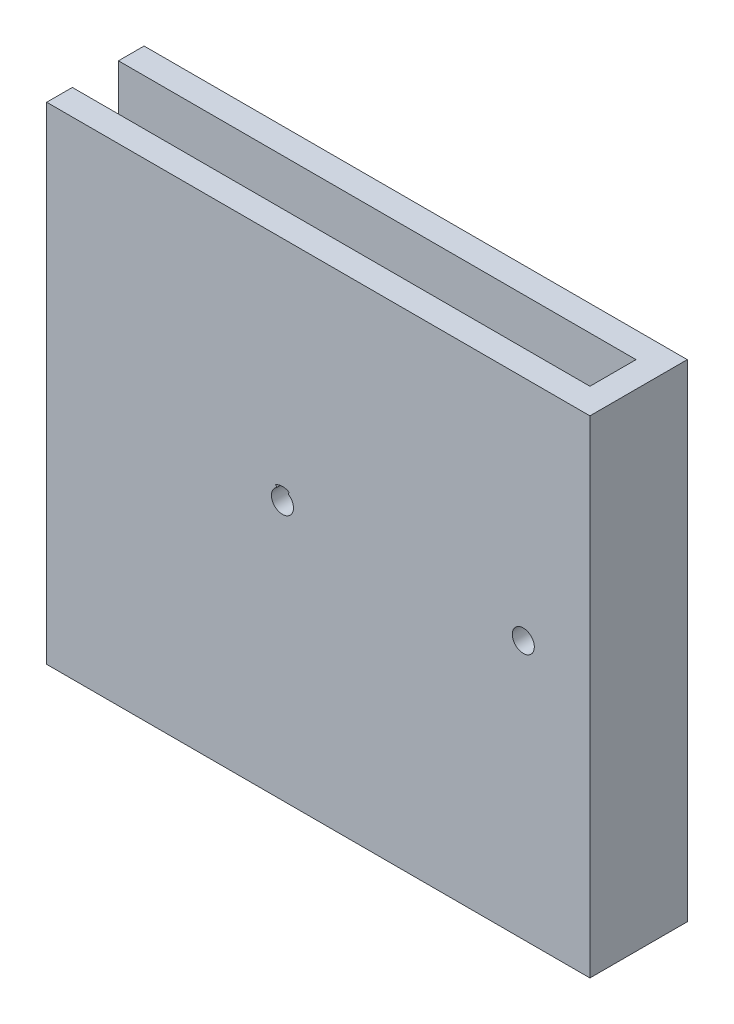
from build123d import *

# Parameters (mm, degrees)
SKETCH1_W           = 101
SKETCH1_H           = 90
BOSS_EXTRUDE1_DEPTH = 5
SKETCH2_W           = 14
SKETCH2_H           = 90
BOSS_EXTRUDE2_DEPTH = 5
SKETCH3_W           = 106
SKETCH3_H           = 90
BOSS_EXTRUDE3_DEPTH = 5
SKETCH4_W           = 106
SKETCH4_H           = 19
BOSS_EXTRUDE4_DEPTH = 5
SKETCH5_R           = 2.15
CUT_EXTRUDE1_DEPTH  = 20
CUT_EXTRUDE2_DEPTH  = 10
CUT_EXTRUDE3_DEPTH  = 10


with BuildPart() as part:
    # Sketch1 → Boss-Extrude1 (new body)
    with BuildSketch(Plane.XY):
        with Locations((30.353658537, 10.426829268)):
            Rectangle(SKETCH1_W, SKETCH1_H)
    extrude(amount=BOSS_EXTRUDE1_DEPTH)

    # Sketch2 → Boss-Extrude2 (add)
    with BuildSketch(Plane(origin=(80.853658537, 0, 0), x_dir=(0, 0, -1), z_dir=(1, 0, 0))):
        with Locations((2, 10.426829268)):
            Rectangle(SKETCH2_W, SKETCH2_H)
    extrude(amount=BOSS_EXTRUDE2_DEPTH)

    # Sketch3 → Boss-Extrude3 (add)
    with BuildSketch(Plane(origin=(0, 0, -9), x_dir=(-1, 0, 0), z_dir=(0, 0, -1))):
        with Locations((-32.853658537, 10.426829268)):
            Rectangle(SKETCH3_W, SKETCH3_H)
    extrude(amount=BOSS_EXTRUDE3_DEPTH)

    # Sketch4 → Boss-Extrude4 (add)
    with BuildSketch(Plane.XZ.offset(34.573170732)):
        with Locations((32.853658537, -4.5)):
            Rectangle(SKETCH4_W, SKETCH4_H)
    extrude(amount=BOSS_EXTRUDE4_DEPTH)

    # Sketch5 → Cut-Extrude1 (cut, through all)
    with BuildSketch(Plane(origin=(0, 0, -14), x_dir=(-1, 0, 0), z_dir=(0, 0, -1))):
        with Locations((-72.853658537, 10.926829268)):
            Circle(SKETCH5_R)
        with Locations((-25.853658537, 10.926829268)):
            Circle(SKETCH5_R)
    extrude(amount=-CUT_EXTRUDE1_DEPTH, mode=Mode.SUBTRACT)

    # Sketch6 → Cut-Extrude2 (cut)
    with BuildSketch(Plane(origin=(0, 0, -14), x_dir=(-1, 0, 0), z_dir=(0, 0, -1))):
        with BuildLine():
            Line((-72.853658537, 10.926829268), (-71.524860303, 13.138320904))
            ThreePointArc((-71.524860303, 13.138320904), (-72.853658537, 13.506829268), (-74.18245677, 13.138320904))
            Line((-74.18245677, 13.138320904), (-72.853658537, 10.926829268))
        make_face()
    extrude(amount=-CUT_EXTRUDE2_DEPTH, mode=Mode.SUBTRACT)

    # Sketch7 → Cut-Extrude3 (cut)
    with BuildSketch(Plane.XY.offset(5)):
        with BuildLine():
            Line((25.853658537, 10.926829268), (27.18245677, 13.138320904))
            ThreePointArc((27.18245677, 13.138320904), (25.853658537, 13.506829268), (24.524860303, 13.138320904))
            Line((24.524860303, 13.138320904), (25.853658537, 10.926829268))
        make_face()
    extrude(amount=-CUT_EXTRUDE3_DEPTH, mode=Mode.SUBTRACT)


solid = part.part
